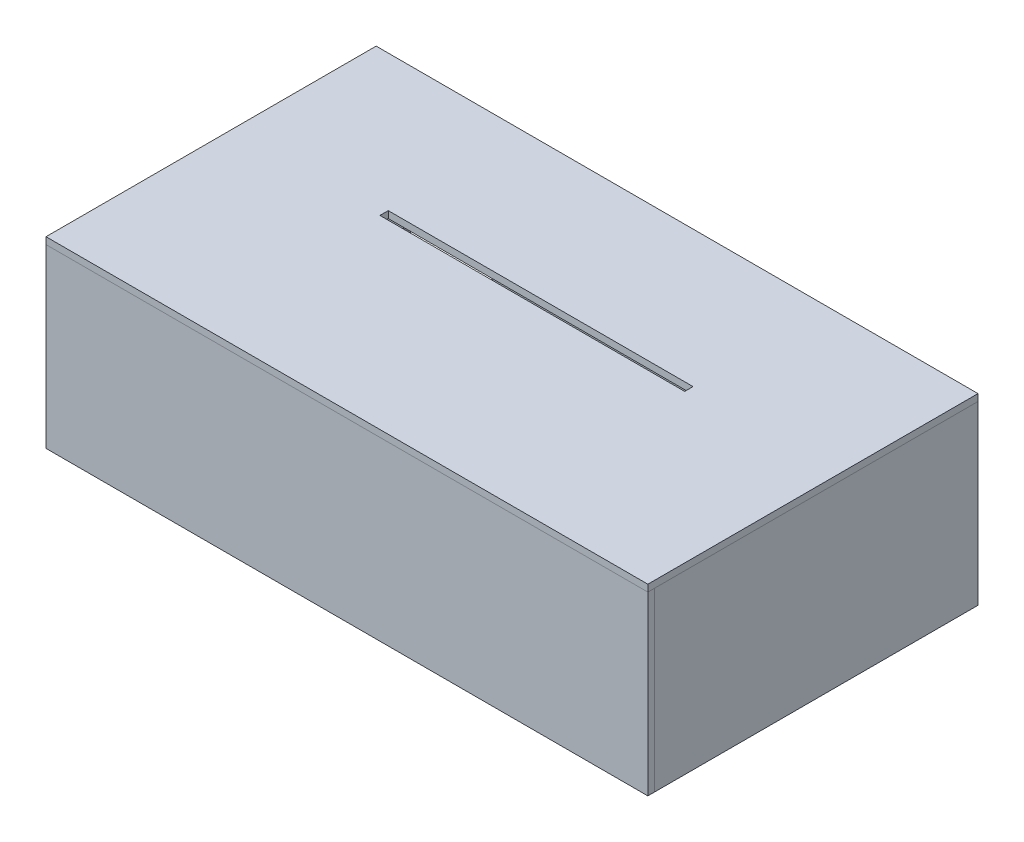
from build123d import *

# Parameters (mm, degrees)
SKETCH1_W           = 457.708
SKETCH1_H           = 251.079
BOSS_EXTRUDE1_DEPTH = 5.207
SKETCH2_W           = 457.708
SKETCH2_H           = 134.239
BOSS_EXTRUDE2_DEPTH = 5.207
CUT_EXTRUDE1_DEPTH  = 117.475
SKETCH3_W           = 245.872
SKETCH3_H           = 134.239
BOSS_EXTRUDE5_DEPTH = 5.207
SKETCH5_W           = 231.775
SKETCH5_H           = 6.35
CUT_EXTRUDE2_DEPTH  = 140.446
SKETCH6_W           = 447.294
SKETCH6_H           = 134.239
BOSS_EXTRUDE6_DEPTH = 5.207
SKETCH7_W           = 2.54
SKETCH7_H           = 0.254
CUT_EXTRUDE3_DEPTH  = 5.207


with BuildPart() as part:
    # Sketch1 → Boss-Extrude1 (new body)
    with BuildSketch(Plane(origin=(0, 0, 0), x_dir=(1, 0, 0), z_dir=(0, 1, 0))):
        Rectangle(SKETCH1_W, SKETCH1_H)
    extrude(amount=BOSS_EXTRUDE1_DEPTH)

    # Sketch5 → Cut-Extrude2 (cut, through all)
    with BuildSketch(Plane(origin=(0, 5.207, 0), x_dir=(1, 0, 0), z_dir=(0, 1, 0))):
        with Locations((0, 18.6055)):
            Rectangle(SKETCH5_W, SKETCH5_H)
    extrude(amount=-CUT_EXTRUDE2_DEPTH, mode=Mode.SUBTRACT)


with BuildPart() as body_2:
    # Sketch2 → Boss-Extrude2 (new body)
    with BuildSketch(Plane.XY.offset(125.5395)):
        with Locations((0, -67.1195)):
            Rectangle(SKETCH2_W, SKETCH2_H)
    extrude(amount=-BOSS_EXTRUDE2_DEPTH)

    # Sketch4 → Cut-Extrude1 (cut, symmetric)
    with BuildSketch(Plane(origin=(0, 0, 0), x_dir=(0, 0, -1), z_dir=(1, 0, 0))):
        Polygon((-125.5395, -134.239), (-120.3325, -129.032), (-120.3325, -134.239), align=None)
    extrude(amount=CUT_EXTRUDE1_DEPTH, both=True, mode=Mode.SUBTRACT)


with BuildPart() as body_3:
    # Sketch3 → Boss-Extrude5 (new body)
    with BuildSketch(Plane(origin=(-228.854, 0, 0), x_dir=(0, 0, -1), z_dir=(1, 0, 0))):
        with Locations((2.6035, -67.1195)):
            Rectangle(SKETCH3_W, SKETCH3_H)
    extrude(amount=BOSS_EXTRUDE5_DEPTH)


with BuildPart() as body_4:
    # Mirror1: mirrored copy
    add(body_3.part.mirror(Plane(origin=(0, 0, 0), x_dir=(0, 0, 1), z_dir=(1, 0, 0))))


with BuildPart() as body_5:
    # Sketch6 → Boss-Extrude6 (new body)
    with BuildSketch(Plane(origin=(0, 0, -125.5395), x_dir=(-1, 0, 0), z_dir=(0, 0, -1))):
        with Locations((0, -67.1195)):
            Rectangle(SKETCH6_W, SKETCH6_H)
        with BuildLine():
            Line((202.8825, -64.389), (202.8825, -112.014))
            ThreePointArc((202.8825, -112.014), (201.022628061, -116.504128061), (196.5325, -118.364))
            Line((196.5325, -118.364), (141.9225, -118.364))
            ThreePointArc((141.9225, -118.364), (137.432371939, -116.504128061), (135.5725, -112.014))
            Line((135.5725, -112.014), (135.5725, -64.389))
            ThreePointArc((135.5725, -64.389), (169.2275, -30.734), (202.8825, -64.389))
        make_face(mode=Mode.SUBTRACT)
    extrude(amount=-BOSS_EXTRUDE6_DEPTH)

    # Sketch7 → Cut-Extrude3 (cut)
    with BuildSketch(Plane(origin=(0, 0, -125.5395), x_dir=(-1, 0, 0), z_dir=(0, 0, -1))):
        with Locations((222.377, -2.667)):
            Rectangle(SKETCH7_W, SKETCH7_H)
        with Locations((-222.377, -2.667)):
            Rectangle(SKETCH7_W, SKETCH7_H)
    extrude(amount=-CUT_EXTRUDE3_DEPTH, mode=Mode.SUBTRACT)


solid = Compound([part.part, body_2.part, body_3.part, body_4.part, body_5.part])
